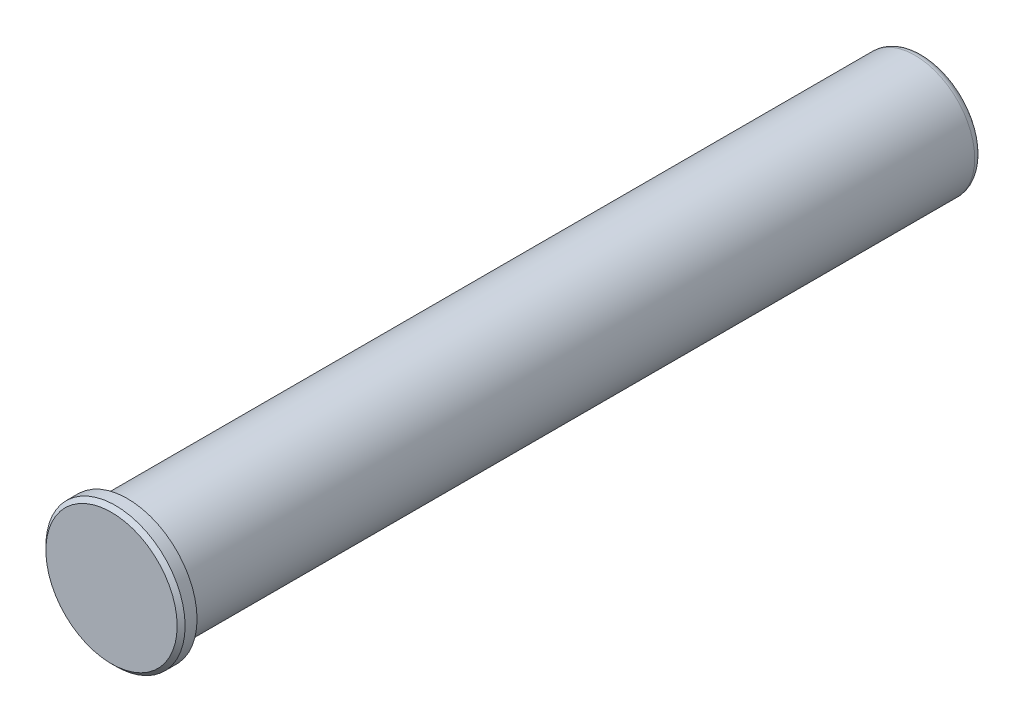
from build123d import *

# Parameters (mm, degrees)
IZIM1_R                     = 15
Y_KSEKLIK_EKSTR_ZYON1_DEPTH = 200
IZIM2_R                     = 17.5
Y_KSEKLIK_EKSTR_ZYON2_DEPTH = 4
RADYUS1_R                   = 0.5
PAH1_SIZE                   = 1
RADYUS2_R                   = 2


with BuildPart() as part:
    # Çizim1 → Yükseklik-Ekstrüzyon1 (new body)
    with BuildSketch(Plane.XY):
        Circle(IZIM1_R)
    extrude(amount=Y_KSEKLIK_EKSTR_ZYON1_DEPTH)

    # Çizim2 → Yükseklik-Ekstrüzyon2 (add)
    with BuildSketch(Plane.XY.offset(200)):
        Circle(IZIM2_R)
    extrude(amount=Y_KSEKLIK_EKSTR_ZYON2_DEPTH)

    # Radyus1
    radyus1_edges = [part.edges().sort_by_distance(p)[0] for p in [
        (-15, 0, 200),
    ]]
    fillet(radyus1_edges, radius=RADYUS1_R)

    # Pah1
    pah1_edges = [part.edges().sort_by_distance(p)[0] for p in [
        (-17.5, 0, 204),
    ]]
    chamfer(pah1_edges, length=PAH1_SIZE)

    # Radyus2
    radyus2_edges = [part.edges().sort_by_distance(p)[0] for p in [
        (-15, 0, 0),
    ]]
    fillet(radyus2_edges, radius=RADYUS2_R)


solid = part.part
